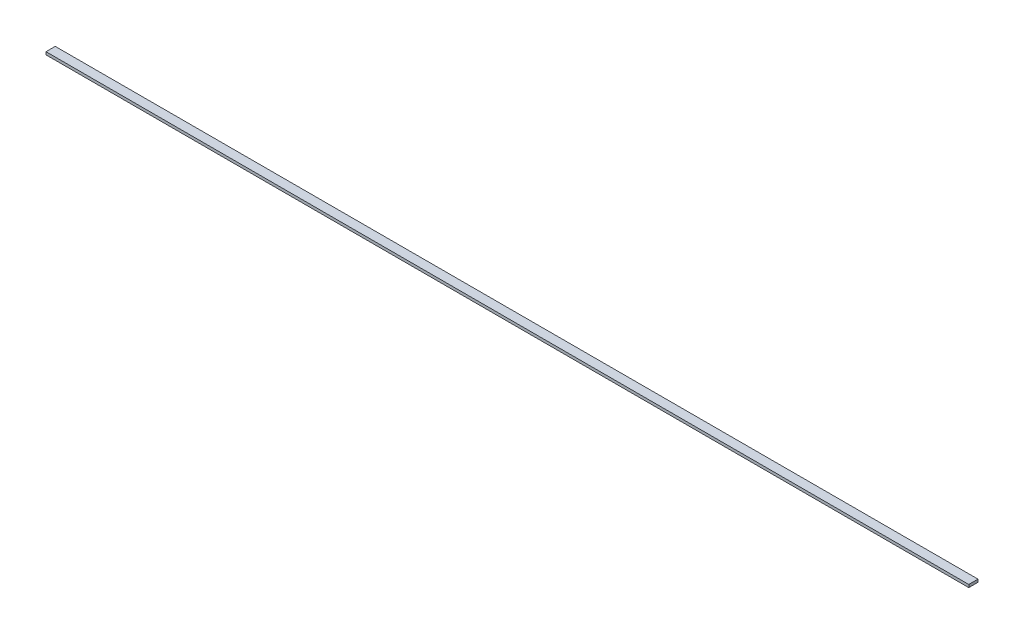
from build123d import *

# Parameters (mm, degrees)
SKETCH1_W           = 1000
SKETCH1_H           = 10
BOSS_EXTRUDE1_DEPTH = 3


with BuildPart() as part:
    # Sketch1 → Boss-Extrude1 (new body)
    with BuildSketch(Plane(origin=(0, 0, 0), x_dir=(1, 0, 0), z_dir=(0, 1, 0))):
        with Locations((500, 5)):
            Rectangle(SKETCH1_W, SKETCH1_H)
    extrude(amount=BOSS_EXTRUDE1_DEPTH)


solid = part.part
